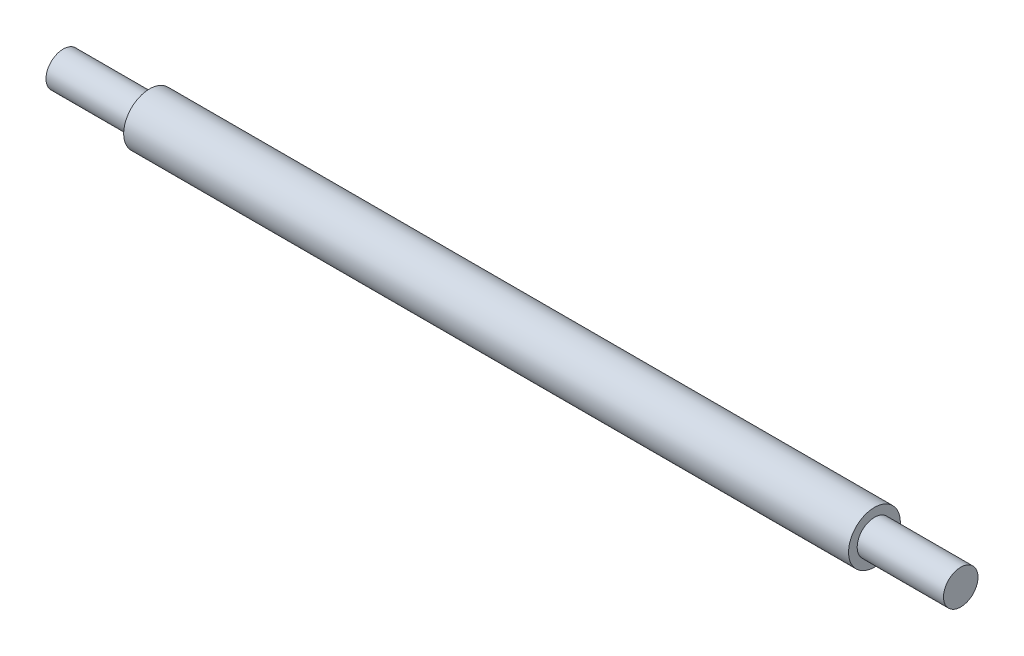
from build123d import *


with BuildPart() as part:
    # Sketch1 → Revolve1 (revolve)
    with BuildSketch(Plane.XY, mode=Mode.PRIVATE) as revolve1_sk:
        Polygon((-52, 0), (-52, 2), (-42, 2), (-42, 3), (42, 3), (42, 2), (52, 2), (52, 0), align=None)
    revolve(revolve1_sk.sketch.rotate(Axis((-52, 0, 0), (1, 0, 0)), 180), axis=Axis((-52, 0, 0), (1, 0, 0)))  # turned: the seam where the file's is


solid = part.part
